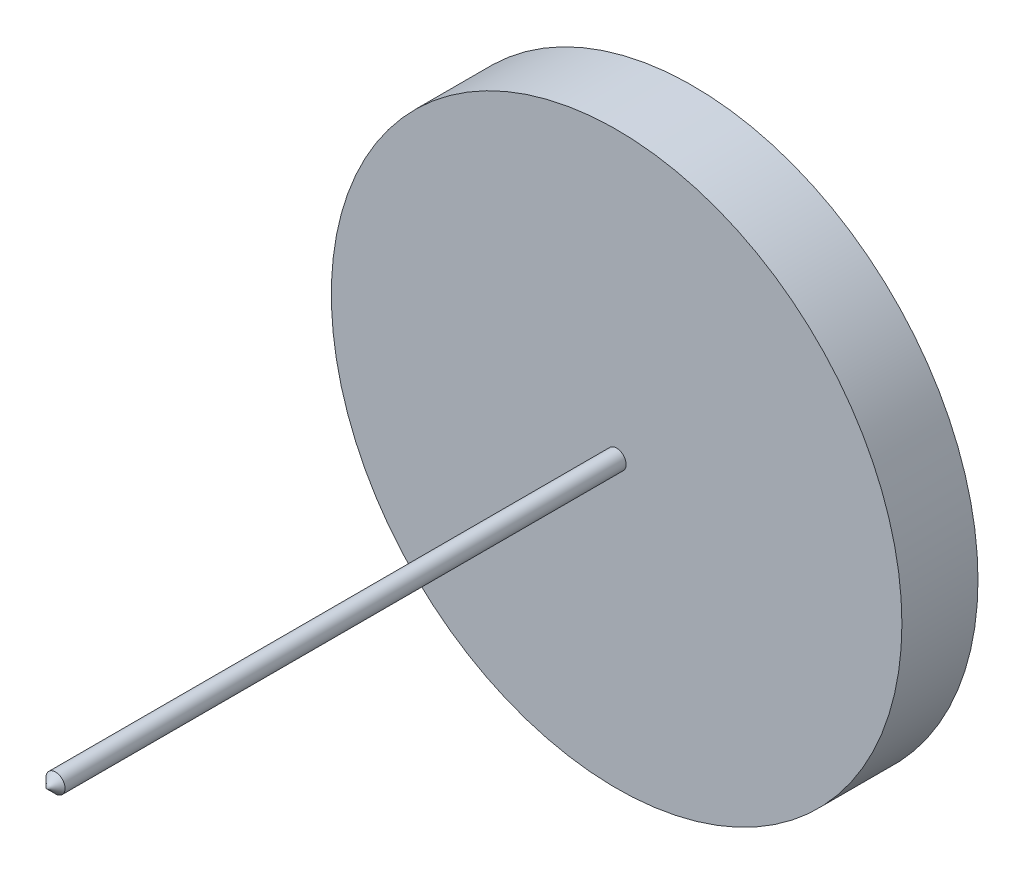
from build123d import *

# Parameters (mm, degrees)
SKETCH1_R           = 7.5
BOSS_EXTRUDE1_DEPTH = 2
SKETCH2_R           = 0.25
BOSS_EXTRUDE2_DEPTH = 15
CHAMFER1_SIZE       = 0.25


with BuildPart() as part:
    # Sketch1 → Boss-Extrude1 (new body)
    with BuildSketch(Plane.XY):
        Circle(SKETCH1_R)
    extrude(amount=BOSS_EXTRUDE1_DEPTH)

    # Sketch2 → Boss-Extrude2 (add)
    with BuildSketch(Plane.XY.offset(2)):
        Circle(SKETCH2_R)
    extrude(amount=BOSS_EXTRUDE2_DEPTH)

    # Chamfer1
    chamfer1_edges = [part.edges().sort_by_distance(p)[0] for p in [
        (-0.25, 0, 17),
    ]]
    chamfer(chamfer1_edges, length=CHAMFER1_SIZE)


solid = part.part
